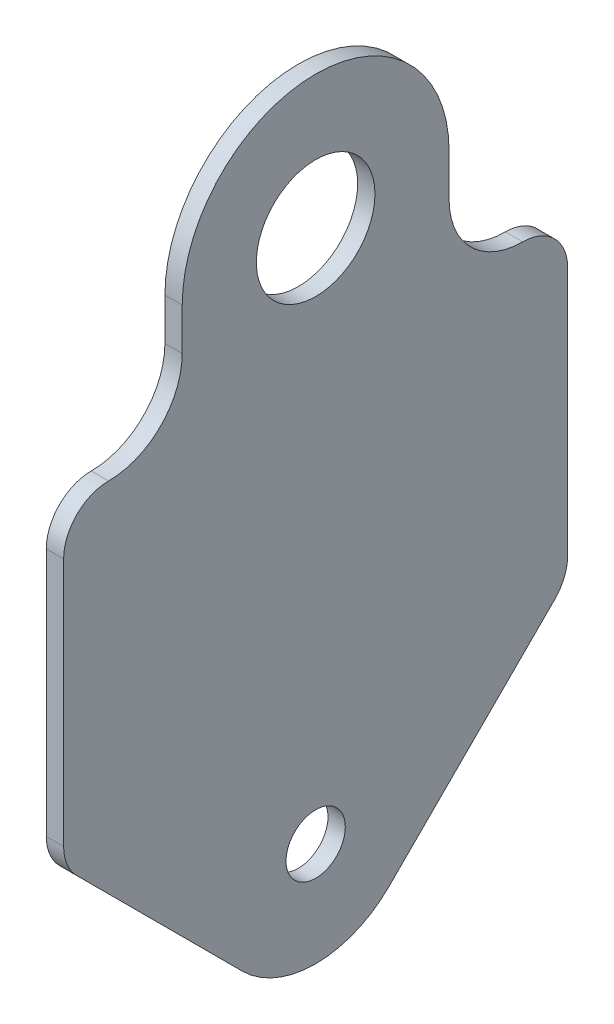
from build123d import *

# Parameters (mm, degrees)
SKETCH1_R           = 8
SKETCH1_R_2         = 4
BOSS_EXTRUDE1_DEPTH = 2.3368


with BuildPart() as part:
    # Sketch1 → Boss-Extrude1 (new body)
    with BuildSketch(Plane(origin=(0, 0, 0), x_dir=(0, 0, -1), z_dir=(1, 0, 0))):
        with BuildLine():
            Line((-18, 0), (-18, -5.640538448))
            ThreePointArc((-18, -5.640538448), (-20.910261619, -12.666531518), (-27.936254688, -15.576793136))
            ThreePointArc((-27.936254688, -15.576793136), (-32.223970118, -17.352823019), (-34, -21.640538448))
            Line((-34, -21.640538448), (-34, -55.247304326))
            ThreePointArc((-34, -55.247304326), (-33.538424872, -57.567799195), (-32.223970118, -59.535019756))
            Line((-32.223970118, -59.535019756), (-9.899494937, -81.859494937))
            ThreePointArc((-9.899494937, -81.859494937), (0, -85.96), (9.899494937, -81.859494937))
            Line((9.899494937, -81.859494937), (32.223970118, -59.535019756))
            ThreePointArc((32.223970118, -59.535019756), (33.538424872, -57.567799195), (34, -55.247304326))
            Line((34, -55.247304326), (34, -21.640538448))
            ThreePointArc((34, -21.640538448), (32.223970118, -17.352823019), (27.936254688, -15.576793136))
            ThreePointArc((27.936254688, -15.576793136), (20.910261619, -12.666531518), (18, -5.640538448))
            Line((18, -5.640538448), (18, 0))
            ThreePointArc((18, 0), (0, 18), (-18, 0))
        make_face()
        Circle(SKETCH1_R, mode=Mode.SUBTRACT)
        with Locations((0, -71.96)):
            Circle(SKETCH1_R_2, mode=Mode.SUBTRACT)
    extrude(amount=BOSS_EXTRUDE1_DEPTH)


solid = part.part
